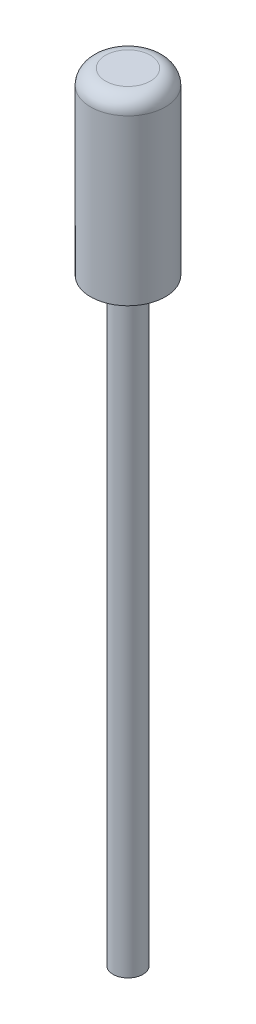
from build123d import *


with BuildPart() as part:
    # Sketch1 → Revolve1 (revolve)
    with BuildSketch(Plane.XY):
        with BuildLine():
            Line((0, 0), (1, 0))
            Line((1, 0), (1, 39.6))
            ThreePointArc((1, 39.6), (1.117157288, 39.882842712), (1.4, 40))
            Line((1.4, 40), (2.5, 40))
            Line((2.5, 40), (2.5, 51))
            ThreePointArc((2.5, 51), (2.207106781, 51.707106781), (1.5, 52))
            Line((1.5, 52), (0, 52))
            Line((0, 52), (0, 0))
        make_face()
    revolve(axis=Axis((0, 52, 0), (0, -1, 0)))


solid = part.part
